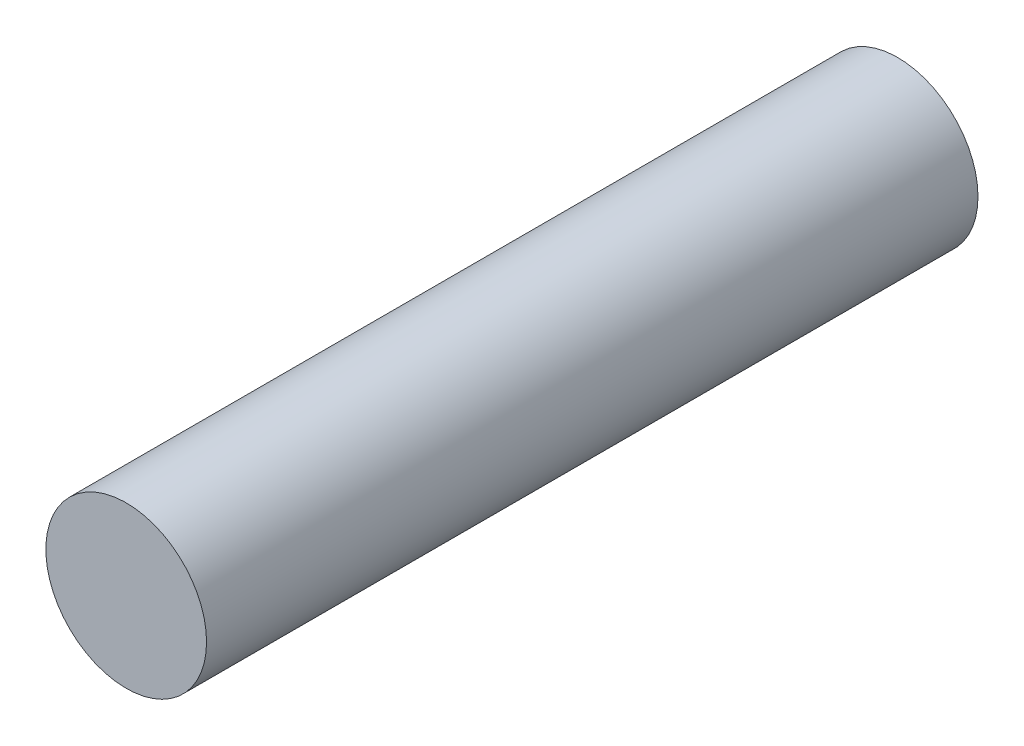
from build123d import *

# Parameters (mm, degrees)
SKETCH1_R           = 7.5
BOSS_EXTRUDE1_DEPTH = 72


with BuildPart() as part:
    # Sketch1 → Boss-Extrude1 (new body)
    with BuildSketch(Plane.XY):
        Circle(SKETCH1_R)
    extrude(amount=BOSS_EXTRUDE1_DEPTH)


solid = part.part
